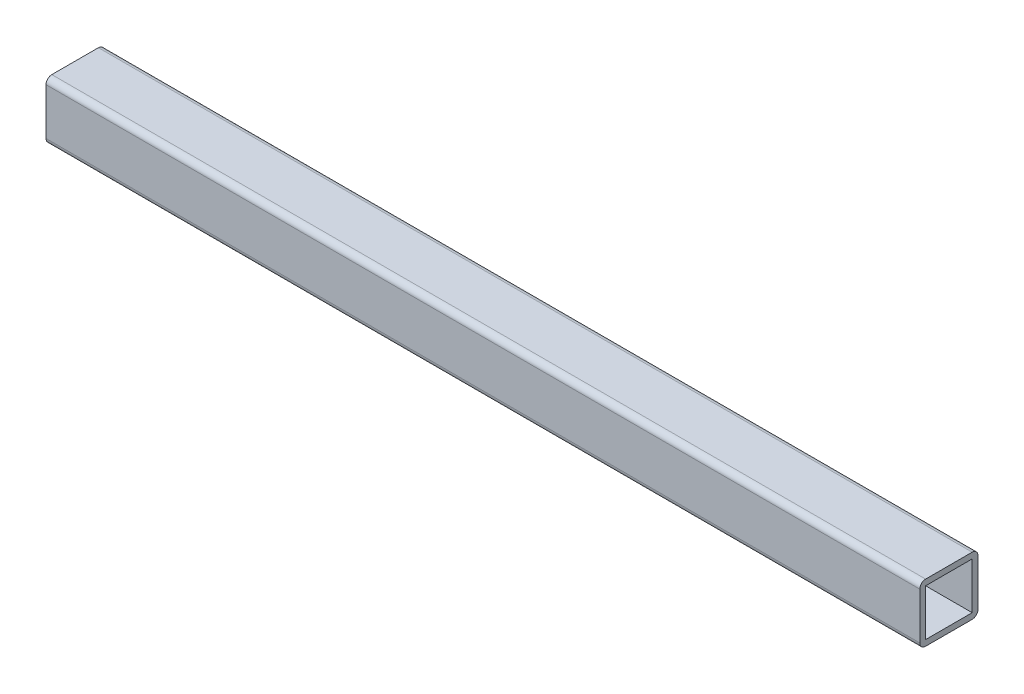
from build123d import *

# Parameters (mm, degrees)
SKETCH1_W           = 300.2
SKETCH1_H           = 20
BOSS_EXTRUDE1_DEPTH = 20
FILLET1_R           = 2
SKETCH2_W           = 16
SKETCH2_H           = 16
CUT_EXTRUDE1_DEPTH  = 301.2


with BuildPart() as part:
    # Sketch1 → Boss-Extrude1 (new body)
    with BuildSketch(Plane.XY):
        with Locations((-440, -302)):
            Rectangle(SKETCH1_W, SKETCH1_H)
    extrude(amount=-BOSS_EXTRUDE1_DEPTH)

    # Fillet1
    fillet1_edges = [part.edges().sort_by_distance(p)[0] for p in [
        (-440, -312, -20),
        (-440, -312, 0),
        (-440, -292, 0),
        (-440, -292, -20),
    ]]
    fillet(fillet1_edges, radius=FILLET1_R)

    # Sketch2 → Cut-Extrude1 (cut, through all)
    with BuildSketch(Plane(origin=(-289.9, 0, 0), x_dir=(0, 0, -1), z_dir=(1, 0, 0))):
        with Locations((10, -302)):
            Rectangle(SKETCH2_W, SKETCH2_H)
    extrude(amount=-CUT_EXTRUDE1_DEPTH, mode=Mode.SUBTRACT)


solid = part.part
